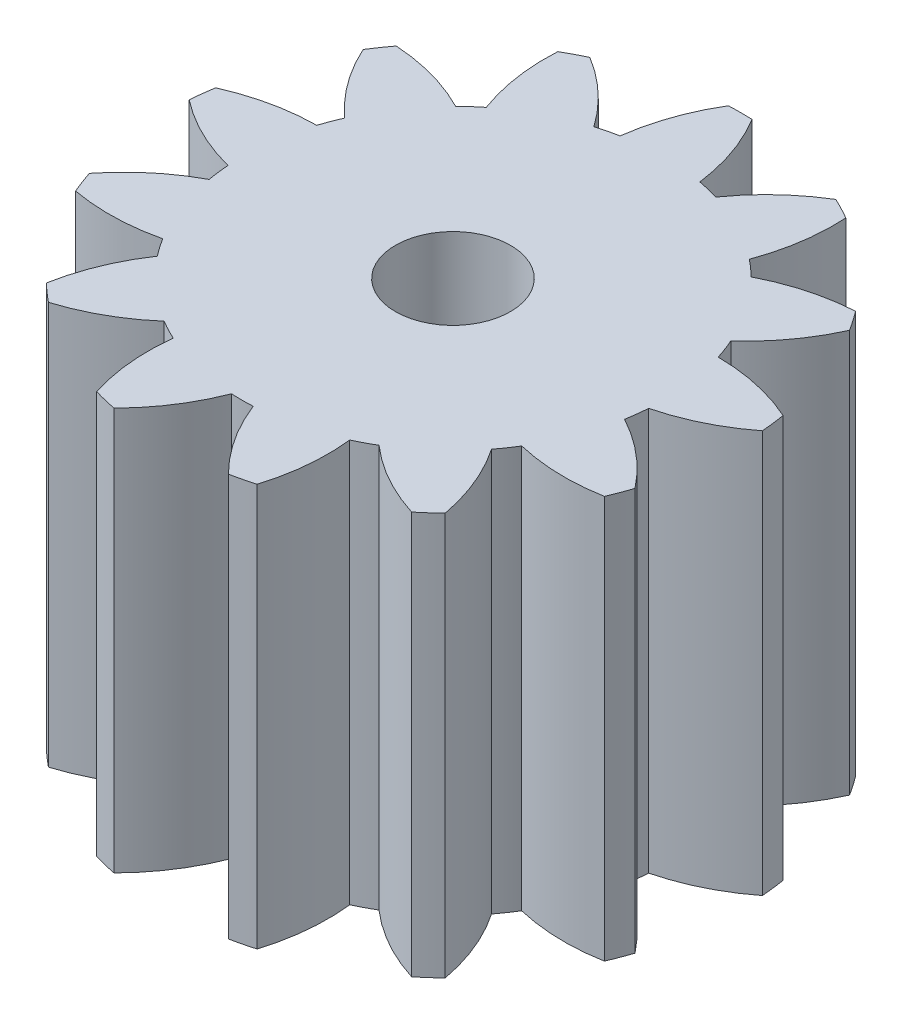
from build123d import *

# Parameters (mm, degrees)
BOSS_EXTRUDE1_DEPTH = 10.5
SKETCH2_R           = 1.5
CUT_EXTRUDE1_DEPTH  = 10.5


with BuildPart() as part:
    # Sketch1 → Boss-Extrude1 (new body)
    with BuildSketch(Plane(origin=(0, 0, 0), x_dir=(1, 0, 0), z_dir=(0, 1, 0))):
        with BuildLine():
            ThreePointArc((1.04, 5.400777722), (0.783531714, 6.485041414), (0.31, 7.493590595))
            ThreePointArc((0.31, 7.493590595), (0, 7.5), (-0.31, 7.493590595))
            ThreePointArc((-0.31, 7.493590595), (-0.783531714, 6.485041414), (-1.04, 5.400777722))
            ThreePointArc((-1.04, 5.400777722), (-1.316236154, 5.340179996), (-1.588992288, 5.265463276))
            ThreePointArc((-1.588992288, 5.265463276), (-2.319966139, 6.10634434), (-3.207953823, 6.779309129))
            ThreePointArc((-3.207953823, 6.779309129), (-3.48542379, 6.640920192), (-3.756936559, 6.491180762))
            ThreePointArc((-3.756936559, 6.491180762), (-3.707531894, 5.378093653), (-3.430740821, 4.298839078))
            ThreePointArc((-3.430740821, 4.298839078), (-3.64717462, 4.116809115), (-3.853965592, 3.923894649))
            ThreePointArc((-3.853965592, 3.923894649), (-4.891987708, 4.328757368), (-5.991004086, 4.511969642))
            ThreePointArc((-5.991004086, 4.511969642), (-6.172378994, 4.2604856), (-6.343204228, 4.001719645))
            ThreePointArc((-6.343204228, 4.001719645), (-5.782181198, 3.039089449), (-5.035540265, 2.212088208))
            ThreePointArc((-5.035540265, 2.212088208), (-5.142589335, 1.950326879), (-5.236041824, 1.683409046))
            ThreePointArc((-5.236041824, 1.683409046), (-6.343313848, 1.559504249), (-7.401587511, 1.210992284))
            ThreePointArc((-7.401587511, 1.210992284), (-7.445316556, 0.904025102), (-7.476320253, 0.595512782))
            ThreePointArc((-7.476320253, 0.595512782), (-6.532202472, 0.003866477), (-5.486758119, -0.381425412))
            ThreePointArc((-5.486758119, -0.381425412), (-5.459898808, -0.662951741), (-5.418603976, -0.942725282))
            ThreePointArc((-5.418603976, -0.942725282), (-6.341463231, -1.567012498), (-7.116556437, -2.367408811))
            ThreePointArc((-7.116556437, -2.367408811), (-7.01262182, -2.659536653), (-6.896701407, -2.947118882))
            ThreePointArc((-6.896701407, -2.947118882), (-5.785774881, -3.032242258), (-4.68102581, -2.887559066))
            ThreePointArc((-4.68102581, -2.887559066), (-4.526411262, -3.124356107), (-4.359829258, -3.352892609))
            ThreePointArc((-4.359829258, -3.352892609), (-4.886859811, -4.334545567), (-5.201208047, -5.403465078))
            ThreePointArc((-5.201208047, -5.403465078), (-4.973419937, -5.613830611), (-4.737131383, -5.814601127))
            ThreePointArc((-4.737131383, -5.814601127), (-3.713895991, -5.373700834), (-2.802926901, -4.732187738))
            ThreePointArc((-2.802926901, -4.732187738), (-2.555977446, -4.870008141), (-2.302270198, -4.994952646))
            ThreePointArc((-2.302270198, -4.994952646), (-2.312735701, -6.109086484), (-2.094325574, -7.201652615))
            ThreePointArc((-2.094325574, -7.201652615), (-1.794867482, -7.282063631), (-1.492341648, -7.350028327))
            ThreePointArc((-1.492341648, -7.350028327), (-0.791208287, -6.484109309), (-0.282711218, -5.492729228))
            ThreePointArc((-0.282711218, -5.492729228), (0, -5.5), (0.282711218, -5.492729228))
            ThreePointArc((0.282711218, -5.492729228), (0.791208287, -6.484109309), (1.492341648, -7.350028327))
            ThreePointArc((1.492341648, -7.350028327), (1.794867482, -7.282063631), (2.094325574, -7.201652615))
            ThreePointArc((2.094325574, -7.201652615), (2.312735701, -6.109086484), (2.302270198, -4.994952646))
            ThreePointArc((2.302270198, -4.994952646), (2.555977446, -4.870008141), (2.802926901, -4.732187738))
            ThreePointArc((2.802926901, -4.732187738), (3.713895991, -5.373700834), (4.737131383, -5.814601127))
            ThreePointArc((4.737131383, -5.814601127), (4.973419937, -5.613830611), (5.201208047, -5.403465078))
            ThreePointArc((5.201208047, -5.403465078), (4.886859811, -4.334545567), (4.359829258, -3.352892609))
            ThreePointArc((4.359829258, -3.352892609), (4.526411262, -3.124356107), (4.68102581, -2.887559066))
            ThreePointArc((4.68102581, -2.887559066), (5.785774881, -3.032242258), (6.896701407, -2.947118882))
            ThreePointArc((6.896701407, -2.947118882), (7.01262182, -2.659536653), (7.116556437, -2.367408811))
            ThreePointArc((7.116556437, -2.367408811), (6.341463231, -1.567012498), (5.418603976, -0.942725282))
            ThreePointArc((5.418603976, -0.942725282), (5.459898808, -0.662951741), (5.486758119, -0.381425412))
            ThreePointArc((5.486758119, -0.381425412), (6.532202472, 0.003866477), (7.476320253, 0.595512782))
            ThreePointArc((7.476320253, 0.595512782), (7.445316556, 0.904025102), (7.401587511, 1.210992284))
            ThreePointArc((7.401587511, 1.210992284), (6.343313848, 1.559504249), (5.236041824, 1.683409046))
            ThreePointArc((5.236041824, 1.683409046), (5.142589335, 1.950326879), (5.035540265, 2.212088208))
            ThreePointArc((5.035540265, 2.212088208), (5.782181198, 3.039089449), (6.343204228, 4.001719645))
            ThreePointArc((6.343204228, 4.001719645), (6.172378994, 4.2604856), (5.991004086, 4.511969642))
            ThreePointArc((5.991004086, 4.511969642), (4.891987708, 4.328757368), (3.853965592, 3.923894649))
            ThreePointArc((3.853965592, 3.923894649), (3.64717462, 4.116809115), (3.430740821, 4.298839078))
            ThreePointArc((3.430740821, 4.298839078), (3.707531894, 5.378093653), (3.756936559, 6.491180762))
            ThreePointArc((3.756936559, 6.491180762), (3.48542379, 6.640920192), (3.207953823, 6.779309129))
            ThreePointArc((3.207953823, 6.779309129), (2.319966139, 6.10634434), (1.588992288, 5.265463276))
            ThreePointArc((1.588992288, 5.265463276), (1.316236154, 5.340179996), (1.04, 5.400777722))
        make_face()
    extrude(amount=BOSS_EXTRUDE1_DEPTH)

    # Sketch2 → Cut-Extrude1 (cut)
    with BuildSketch(Plane(origin=(0, 10.5, 0), x_dir=(1, 0, 0), z_dir=(0, 1, 0))):
        Circle(SKETCH2_R)
    extrude(amount=-CUT_EXTRUDE1_DEPTH, mode=Mode.SUBTRACT)


solid = part.part
